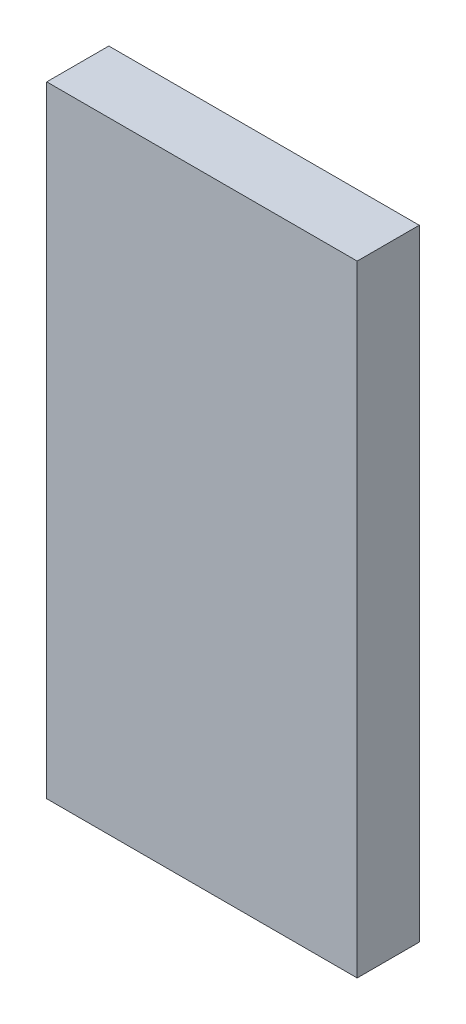
from build123d import *

# Parameters (mm, degrees)
SKICA1_W                = 50
SKICA1_H                = 100
P_IDAT_VYSUNUT_M1_DEPTH = 10


with BuildPart() as part:
    # Skica1 → Přidat vysunutím1 (new body)
    with BuildSketch(Plane.XY):
        Rectangle(SKICA1_W, SKICA1_H)
    extrude(amount=P_IDAT_VYSUNUT_M1_DEPTH)


solid = part.part
